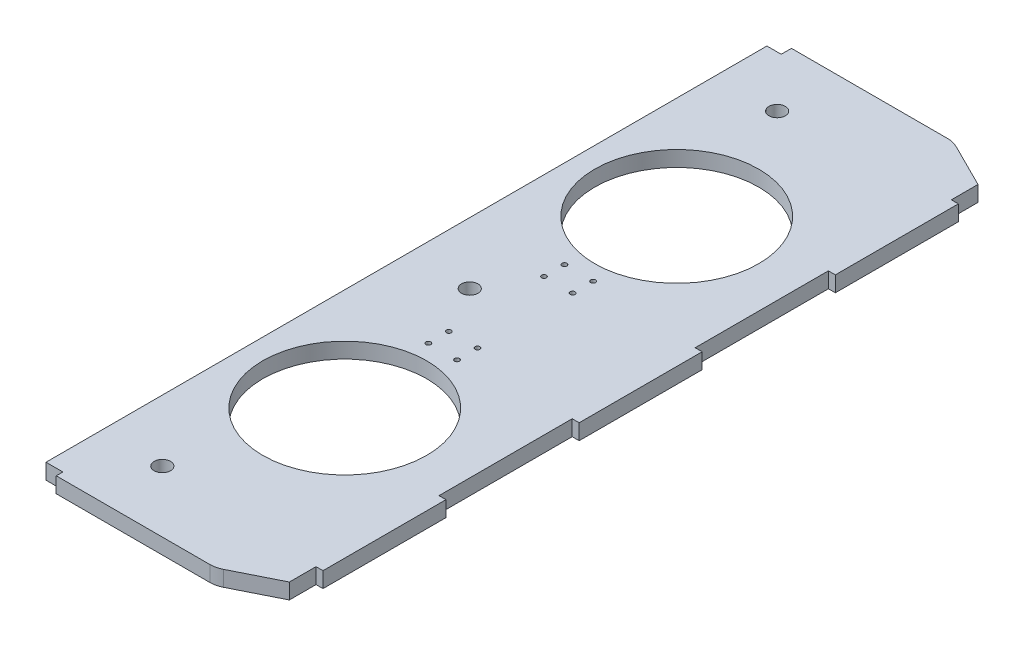
from build123d import *

# Parameters (mm, degrees)
SKETCH1_W                    = 139.7
SKETCH1_H                    = 457.2
SKETCH1_R                    = 50.8
SKETCH1_R_2                  = 5.08
BOSS_EXTRUDE1_DEPTH          = 9.652
SKETCH4_W                    = 10.452383168
SKETCH4_H                    = 4.1148
SKETCH4_W_2                  = 8.864883168
SKETCH4_H_2                  = 6.35
CUT_EXTRUDE1_DEPTH           = 10.652
CHAMFER1_SIZE                = 15.24
CHAMFER1_SIZE2               = 30.48
CHAMFER2_SIZE                = 30.48
CHAMFER2_SIZE2               = 15.24
FILLET2_R                    = 15.24
SKETCH5_W                    = 76.2
SKETCH5_H                    = 9.652
BOSS_EXTRUDE2_DEPTH          = 4.318
F_3_0_3_DIAMETER_HOLE1_D     = 3
F_3_0_3_DIAMETER_HOLE1_DEPTH = 9.652


with BuildPart() as part:
    # Sketch1 → Boss-Extrude1 (new body)
    with BuildSketch(Plane(origin=(0, 0, 0), x_dir=(1, 0, 0), z_dir=(0, 1, 0))):
        with Locations((69.85, 228.6)):
            Rectangle(SKETCH1_W, SKETCH1_H)
        with Locations((63.5, 125.73)):
            Circle(SKETCH1_R, mode=Mode.SUBTRACT)
        with Locations((38.1, 38.1)):
            Circle(SKETCH1_R_2, mode=Mode.SUBTRACT)
        with Locations((38.1, 419.1)):
            Circle(SKETCH1_R_2, mode=Mode.SUBTRACT)
        with Locations((63.5, 331.47)):
            Circle(SKETCH1_R, mode=Mode.SUBTRACT)
        with Locations((38.1, 228.6)):
            Circle(SKETCH1_R_2, mode=Mode.SUBTRACT)
    extrude(amount=BOSS_EXTRUDE1_DEPTH)

    # Sketch4 → Cut-Extrude1 (cut, through all)
    with BuildSketch(Plane(origin=(0, 9.652, 0), x_dir=(1, 0, 0), z_dir=(0, 1, 0))):
        with Locations((5.226191584, 2.0574)):
            Rectangle(SKETCH4_W, SKETCH4_H)
        with Locations((4.432441584, 454.025)):
            Rectangle(SKETCH4_W_2, SKETCH4_H_2)
    extrude(amount=-CUT_EXTRUDE1_DEPTH, mode=Mode.SUBTRACT)

    # Chamfer1
    chamfer1_edges = [part.edges().sort_by_distance(p)[0] for p in [
        (139.7, 4.826, -457.2),
    ]]
    chamfer1_side = [part.faces().sort_by_distance(p)[0] for p in [
        (139.7, 4.826, -228.6),
    ]]
    chamfer(chamfer1_edges, length=CHAMFER1_SIZE, length2=CHAMFER1_SIZE2, reference=chamfer1_side[0])

    # Chamfer2
    chamfer2_edges = [part.edges().sort_by_distance(p)[0] for p in [
        (139.7, 4.826, 0),
    ]]
    chamfer2_side = [part.faces().sort_by_distance(p)[0] for p in [
        (75.076191584, 4.826, 0),
    ]]
    chamfer(chamfer2_edges, length=CHAMFER2_SIZE, length2=CHAMFER2_SIZE2, reference=chamfer2_side[0])

    # Fillet2
    fillet2_edges = [part.edges().sort_by_distance(p)[0] for p in [
        (109.22, 4.826, -457.2),
        (109.22, 4.826, 0),
    ]]
    fillet(fillet2_edges, radius=FILLET2_R)

    # Sketch5 → Boss-Extrude2 (add)
    with BuildSketch(Plane(origin=(139.7, 0, 0), x_dir=(0, 0, -1), z_dir=(1, 0, 0))):
        with Locations((69.85, 4.826)):
            Rectangle(SKETCH5_W, SKETCH5_H)
        with Locations((228.6, 4.826)):
            Rectangle(SKETCH5_W, SKETCH5_H)
        with Locations((387.35, 4.826)):
            Rectangle(SKETCH5_W, SKETCH5_H)
    extrude(amount=BOSS_EXTRUDE2_DEPTH)

    # Ø3.0 (3) Diameter Hole1
    with Locations(Plane(origin=(0, 9.652, 0), x_dir=(1, 0, 0), z_dir=(0, 1, 0))):
        with Locations((72.39, 186.436), (54.61, 186.436), (54.61, 199.136), (72.39, 199.136)):
            f_3_0_3_diameter_hole1 = Hole(F_3_0_3_DIAMETER_HOLE1_D / 2, depth=F_3_0_3_DIAMETER_HOLE1_DEPTH)

    # Mirror1: Ø3.0 (3) Diameter Hole1 across plane
    add(f_3_0_3_diameter_hole1.mirror(Plane.XY.offset(-228.6)), mode=Mode.SUBTRACT)


solid = part.part
